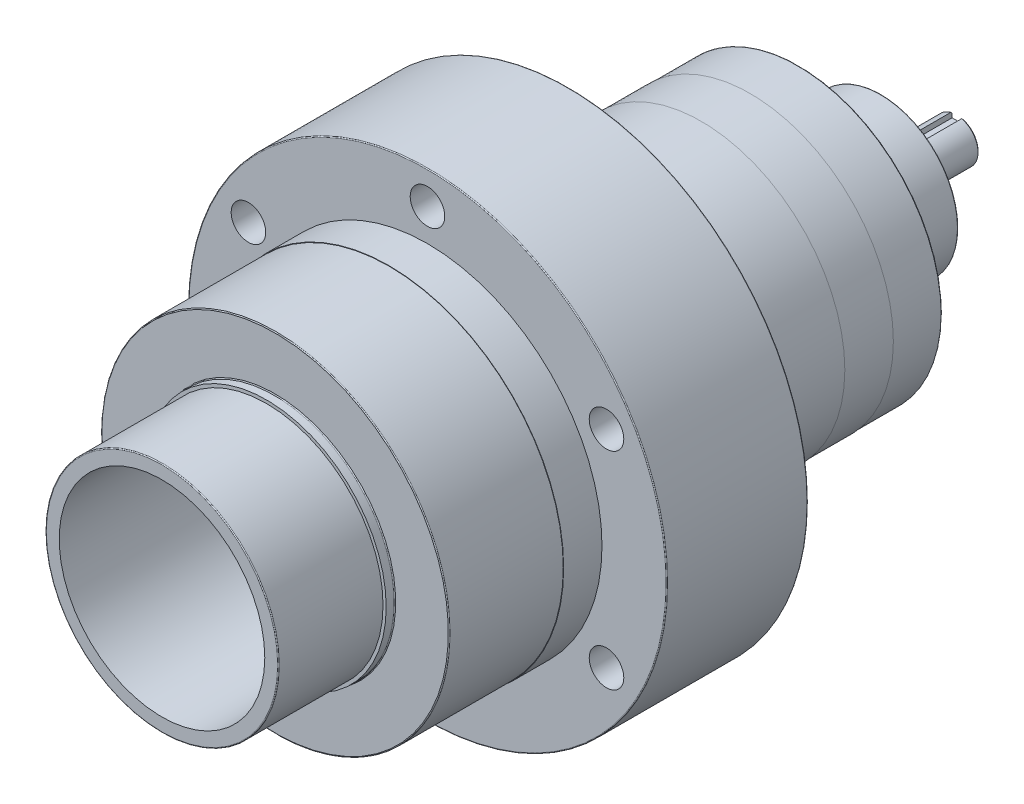
from build123d import *

# Parameters (mm, degrees)
SKETCH1_R                 = 34.925
EXTRUDE_E_DEPTH           = 33.02
SKETCH2_R                 = 34.925
SKETCH2_R_2               = 33.9979
FROM_DRAWING_DEPTH        = 30.5054
SKETCH3_R                 = 50.8
EXTRUDE_C_DEPTH           = 44.45
SKETCH4_R                 = 50.927
SKETCH4_R_2               = 50.8
BOSS_EXTRUDE3_DEPTH       = 11.176
SKETCH5_R                 = 69.85
EXTRUDE_B_DEPTH           = 41.148
CUT_EXTRUDE_START         = -76.2
SKETCH6_R                 = 29.9974
CUT_EXTRUDE_F_DEPTH       = 76.2
SKETCH8_R                 = 41.656
EXTRUDE_D_DEPTH           = 67.31
BOSS_EXTRUDE6_START       = 14.2875
SKETCH9_R                 = 41.783
BOSS_EXTRUDE6_DEPTH       = 14.2875
SKETCH10_R                = 41.91
BOSS_EXTRUDE7_DEPTH       = 38.735
SKETCH11_R                = 25.4
FROM_DRAWING_2_DEPTH      = 7.9248
SKETCH12_R                = 22.5044
EXTRUDE_Q_DEPTH           = 16.002
SKETCH13_R                = 6.35
EXTRUDE_R_DEPTH           = 22.3012
HOLE_WIZARD_S_D           = 10.0838
HOLE_WIZARD_S_CBORE_D     = 15.875
HOLE_WIZARD_S_CBORE_DEPTH = 9.525
CIRPATTERN1_COUNT         = 6
SKETCH16_R                = 17.526
SKETCH16_R_2              = 6.35
CUT_EXTRUDE3_DEPTH        = 12.7
CUT_EXTRUDE_T_DEPTH       = 66.278
CHAMFER1_SIZE             = 0.381
FILLET1_R                 = 0.254


with BuildPart() as part:
    # Sketch1 → Extrude E (new body)
    with BuildSketch(Plane.XY):
        Circle(SKETCH1_R)
    extrude(amount=-EXTRUDE_E_DEPTH)

    # Sketch2 → from drawing (cut)
    with BuildSketch(Plane.XY):
        Circle(SKETCH2_R)
        Circle(SKETCH2_R_2, mode=Mode.SUBTRACT)
    extrude(amount=-FROM_DRAWING_DEPTH, mode=Mode.SUBTRACT)

    # Sketch3 → Extrude C (add)
    with BuildSketch(Plane(origin=(0, 0, -33.02), x_dir=(-1, 0, 0), z_dir=(0, 0, -1))):
        with Locations(Location((0, 0, 0), (0, 0, 180))):  # turned: the seam where the file's is
            Circle(SKETCH3_R)
    extrude(amount=EXTRUDE_C_DEPTH)

    # Sketch4 → Boss-Extrude3 (add)
    with BuildSketch(Plane.XY.offset(-66.294)):
        Circle(SKETCH4_R)
        Circle(SKETCH4_R_2, mode=Mode.SUBTRACT)
    extrude(amount=-BOSS_EXTRUDE3_DEPTH)

    # Sketch5 → Extrude B (add)
    with BuildSketch(Plane.XY.offset(-77.47)):
        Circle(SKETCH5_R)
    extrude(amount=-EXTRUDE_B_DEPTH)

    # Sketch6 → Cut-Extrude F (cut)
    with BuildSketch(Plane.XY.offset(CUT_EXTRUDE_START)):
        Circle(SKETCH6_R)
    extrude(amount=CUT_EXTRUDE_F_DEPTH, mode=Mode.SUBTRACT)

    # Sketch8 → Extrude D (add)
    with BuildSketch(Plane(origin=(0, 0, -118.618), x_dir=(-1, 0, 0), z_dir=(0, 0, -1))):
        with Locations(Location((0, 0, 0), (0, 0, 180))):  # turned: the seam where the file's is
            Circle(SKETCH8_R)
    extrude(amount=EXTRUDE_D_DEPTH)

    # Sketch9 → Boss-Extrude6 (add)
    with BuildSketch(Plane.XY.offset(-185.928).offset(BOSS_EXTRUDE6_START)):
        Circle(SKETCH9_R)
    extrude(amount=BOSS_EXTRUDE6_DEPTH)

    # Sketch10 → Boss-Extrude7 (add)
    with BuildSketch(Plane.XY.offset(-157.353)):
        Circle(SKETCH10_R)
    extrude(amount=BOSS_EXTRUDE7_DEPTH)

    # Sketch11 → from drawing 2 (add)
    with BuildSketch(Plane(origin=(0, 0, -185.928), x_dir=(-1, 0, 0), z_dir=(0, 0, -1))):
        with Locations(Location((0, 0, 0), (0, 0, 180))):  # turned: the seam where the file's is
            Circle(SKETCH11_R)
    extrude(amount=FROM_DRAWING_2_DEPTH)

    # Sketch12 → Extrude Q (add)
    with BuildSketch(Plane(origin=(0, 0, -193.8528), x_dir=(-1, 0, 0), z_dir=(0, 0, -1))):
        with Locations(Location((0, 0, 0), (0, 0, 180))):  # turned: the seam where the file's is
            Circle(SKETCH12_R)
    extrude(amount=EXTRUDE_Q_DEPTH)

    # Sketch13 → Extrude R (add)
    with BuildSketch(Plane(origin=(0, 0, -209.8548), x_dir=(-1, 0, 0), z_dir=(0, 0, -1))):
        with Locations(Location((0, 0, 0), (0, 0, 180))):  # turned: the seam where the file's is
            Circle(SKETCH13_R)
    extrude(amount=EXTRUDE_R_DEPTH)

    # Hole Wizard S (through all)
    with Locations(Plane(origin=(0, 0, -118.618), x_dir=(-1, 0, 0), z_dir=(0, 0, -1))):
        with Locations((0, -60.325)):
            hole_wizard_s = CounterBoreHole(HOLE_WIZARD_S_D / 2, HOLE_WIZARD_S_CBORE_D / 2, HOLE_WIZARD_S_CBORE_DEPTH)

    # CirPattern1: Hole Wizard S ×6 about axis
    cirpattern1_axis = Axis((0, 0, 0), (0, 0, 1))
    for i in range(1, CIRPATTERN1_COUNT):
        add(hole_wizard_s.rotate(cirpattern1_axis, i * 360 / CIRPATTERN1_COUNT), mode=Mode.SUBTRACT)

    # Sketch16 → Cut-Extrude3 (cut)
    with BuildSketch(Plane(origin=(0, 0, -209.8548), x_dir=(-1, 0, 0), z_dir=(0, 0, -1))):
        Circle(SKETCH16_R)
        with Locations(Location((0, 0, 0), (0, 0, 180))):  # turned: the seam where the file's is
            Circle(SKETCH16_R_2, mode=Mode.SUBTRACT)
    extrude(amount=-CUT_EXTRUDE3_DEPTH, mode=Mode.SUBTRACT)

    # Sketch17 → Cut-Extrude T (cut, through all)
    with BuildSketch(Plane.XZ.offset(-4.572)):
        with BuildLine():
            Line((-1.5875, -232.156), (-1.5875, -213.106))
            ThreePointArc((-1.5875, -213.106), (0, -211.5185), (1.5875, -213.106))
            Line((1.5875, -213.106), (1.5875, -232.156))
            ThreePointArc((1.5875, -232.156), (0, -233.7435), (-1.5875, -232.156))
        make_face()
    extrude(amount=-CUT_EXTRUDE_T_DEPTH, mode=Mode.SUBTRACT)

    # Chamfer1
    chamfer1_edges = [part.edges().sort_by_distance(p)[0] for p in [
        (-3.888564967, -5.020115786, -232.156),
    ]]
    chamfer(chamfer1_edges, length=CHAMFER1_SIZE)

    # Fillet1
    fillet1_edges = [part.edges().sort_by_distance(p)[0] for p in [
        (-48.274232483, -37.036576643, -118.618),
        (-33.9979, 0, 0),
        (-50.8, 0, -33.02),
        (-69.85, 0, -77.47),
        (-69.85, 0, -118.618),
        (-41.656, 0, -185.928),
        (-34.925, 0, -33.02),
        (-41.91, 0, -118.618),
        (-25.4, 0, -185.928),
        (-25.4, 0, -193.8528),
        (-22.5044, 0, -193.8528),
        (-22.5044, 0, -209.8548),
        (7.9375, -60.325, -118.618),
        (56.211732483, -23.288423357, -118.618),
        (48.274232483, 37.036576643, -118.618),
        (-7.9375, 60.325, -118.618),
        (-56.211732483, 23.288423357, -118.618),
    ]]
    fillet(fillet1_edges, radius=FILLET1_R)


solid = part.part
